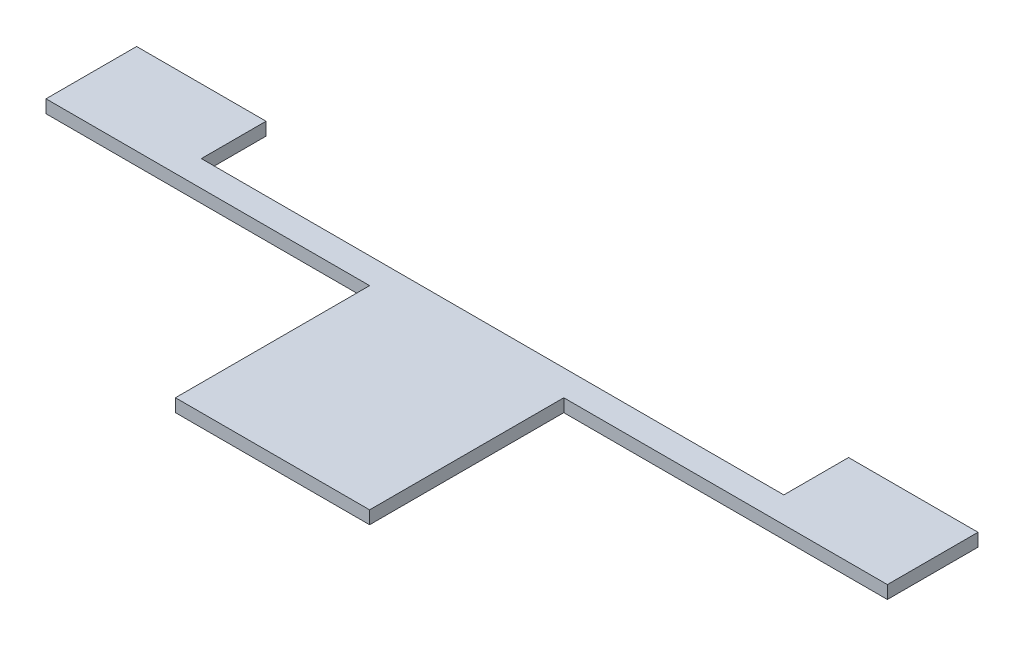
from build123d import *

# Parameters (mm, degrees)
SKETCH1_W           = 30
SKETCH1_H           = 30
BOSS_EXTRUDE1_DEPTH = 2


with BuildPart() as part:
    # Sketch1 → Boss-Extrude1 (new body)
    with BuildSketch(Plane(origin=(0, 0, 0), x_dir=(1, 0, 0), z_dir=(0, 1, 0))):
        Polygon((-78.598325024, 37.862631579), (-78.598325024, 23.862631579), (-28.598325024, 23.862631579), (1.401674976, 23.862631579), (51.401674976, 23.862631579), (51.401674976, 37.862631579), (31.401674976, 37.862631579), (31.401674976, 27.862631579), (-58.598325024, 27.862631579), (-58.598325024, 37.862631579), align=None)
        with Locations((-13.598325024, 8.862631579)):
            Rectangle(SKETCH1_W, SKETCH1_H)
    extrude(amount=BOSS_EXTRUDE1_DEPTH)


solid = part.part
